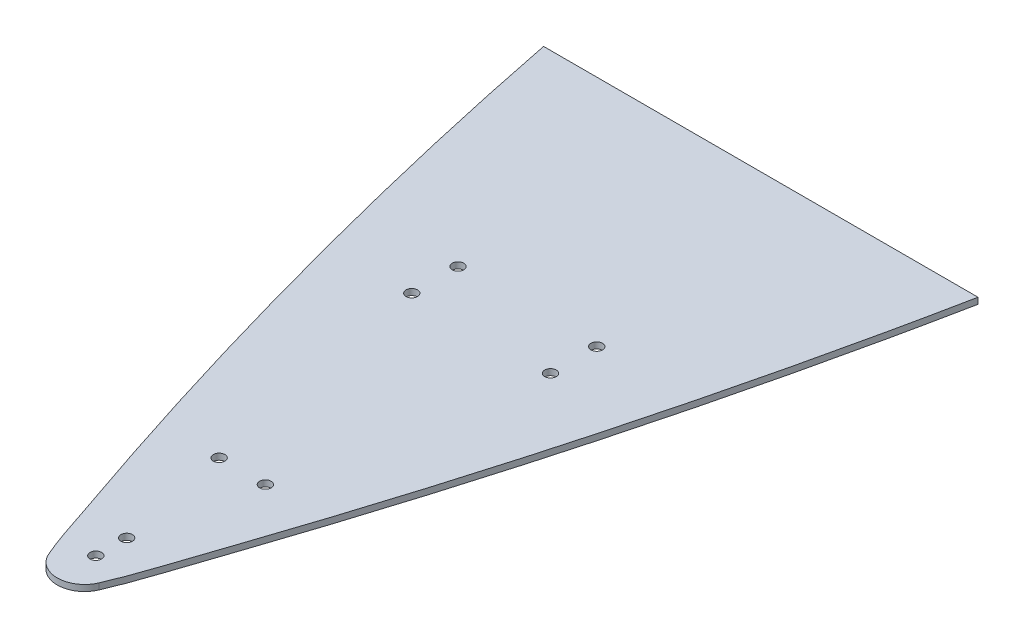
from build123d import *

# Parameters (mm, degrees)
BOSS_EXTRUDE1_DEPTH          = 5.08
F_3_8_0_375_DIAMETER_HOLE1_D = 9.525
F_3_8_0_375_DIAMETER_HOLE2_D = 9.525


with BuildPart() as part:
    # Sketch1 → Boss-Extrude1 (new body)
    with BuildSketch(Plane(origin=(0, 0, 0), x_dir=(1, 0, 0), z_dir=(0, 1, 0))):
        with BuildLine():
            Line((186.706216966, -778.102360844), (-171.269771153, -778.102360844))
            add(Edge.make_bspline(
                [(-171.269771153, -778.102360844), (-159.707774454, -836.134775395), (-146.81892484, -893.9188082), (-132.611103769, -951.360767835), (-118.403260068, -1008.802818957), (-102.873342202, -1065.933903144), (-86.045569786, -1122.663773012), (-74.990089761, -1159.934062127), (-63.371281317, -1197.041907081), (-51.194215445, -1233.960969312), (-45.100567198, -1252.436009294), (-38.866841431, -1270.865430421), (-32.494599583, -1289.246240662), (-26.120797202, -1307.631552278), (-20.652525047, -1326.386680917), (-12.917829919, -1344.242199148)],
                knots=[0, 0, 0, 0, 0.177518923, 0.177518923, 0.177518923, 0.355038121, 0.355038121, 0.355038121, 0.471646972, 0.471646972, 0.471646972, 0.529995372, 0.529995372, 0.529995372, 0.588358391, 0.588358391, 0.588358391, 0.588358391], degree=3))
            ThreePointArc((-12.917829919, -1344.242199148), (7.718222897, -1357.79203399), (28.354275723, -1344.242199164))
            add(Edge.make_bspline(
                [(28.354275723, -1344.242199164), (38.120725658, -1321.696381858), (44.939237661, -1298.079369173), (60.823654171, -1251.671639351), (68.544496879, -1228.393431097), (91.029194373, -1158.368706478), (105.122355407, -1111.420274649), (144.723795491, -969.782644477), (167.537266257, -874.315888923), (186.706216966, -778.102360844)],
                knots=[0, 0, 0, 0, 0.125, 0.125, 0.25, 0.25, 0.5, 0.5, 1, 1, 1, 1], degree=3))
        make_face()
    extrude(amount=BOSS_EXTRUDE1_DEPTH)

    # 3/8 (0.375) Diameter Hole1 (through all)
    with Locations(Plane(origin=(0, 5.08, 0), x_dir=(1, 0, 0), z_dir=(0, 1, 0))):
        with Locations((7.718222897, -1326.04203399), (7.718222897, -1300.64203399)):
            Hole(F_3_8_0_375_DIAMETER_HOLE1_D / 2)

    # 3/8 (0.375) Diameter Hole2 (through all)
    with Locations(Plane(origin=(0, 5.08, 0), x_dir=(1, 0, 0), z_dir=(0, 1, 0))):
        with Locations((-49.431777094, -970.44203399), (-49.431777094, -1008.54203399), (64.868222906, -970.44203399), (64.868222906, -1008.54203399), (-11.331777094, -1205.39203399), (26.768222906, -1205.39203399)):
            Hole(F_3_8_0_375_DIAMETER_HOLE2_D / 2)


solid = part.part
